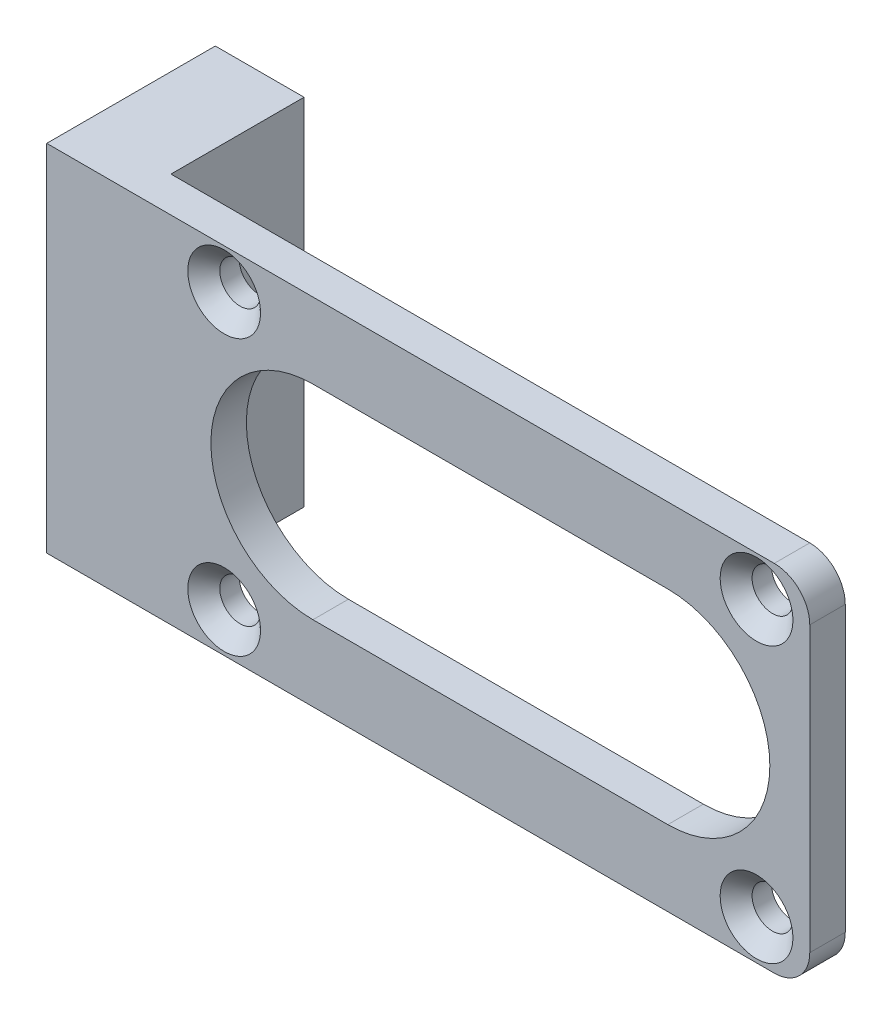
from build123d import *

# Parameters (mm, degrees)
SKETCH1_W           = 38
SKETCH1_H           = 20
BOSS_EXTRUDE1_DEPTH = 2
SKETCH2_W           = 5
SKETCH2_H           = 20
BOSS_EXTRUDE2_DEPTH = 7
M3_TAPPED_HOLE1_D   = 2.5
SKETCH7_R           = 1.15
CUT_EXTRUDE1_DEPTH  = 7.5
CUT_EXTRUDE2_DEPTH  = 7.5
SKETCH9_W           = 5
SKETCH9_H           = 20
BOSS_EXTRUDE3_DEPTH = 2.5
FILLET1_R           = 2
CHAMFER1_SIZE       = 0.9


with BuildPart() as part:
    # Sketch1 → Boss-Extrude1 (new body)
    with BuildSketch(Plane.XY):
        with Locations((19, 10)):
            Rectangle(SKETCH1_W, SKETCH1_H)
    extrude(amount=BOSS_EXTRUDE1_DEPTH)

    # Sketch2 → Boss-Extrude2 (add)
    with BuildSketch(Plane.XY.offset(2)):
        with Locations((-2.5, 10)):
            Rectangle(SKETCH2_W, SKETCH2_H)
    extrude(amount=-BOSS_EXTRUDE2_DEPTH)

    # M3 Tapped Hole1 (through all)
    with Locations(Plane(origin=(-5, 10, -2.5), x_dir=(0, -1, 0), z_dir=(-1, 0, 0))):
        with Locations((0, 0)):
            Hole(M3_TAPPED_HOLE1_D / 2)

    # Sketch7 → Cut-Extrude1 (cut)
    with BuildSketch(Plane.XY.offset(2)):
        with Locations((35, 17.75)):
            Circle(SKETCH7_R)
        with Locations((5, 17.75)):
            Circle(SKETCH7_R)
        with Locations((35, 2.25)):
            Circle(SKETCH7_R)
        with Locations((5, 2.25)):
            Circle(SKETCH7_R)
    extrude(amount=-CUT_EXTRUDE1_DEPTH, mode=Mode.SUBTRACT)

    # Sketch8 → Cut-Extrude2 (cut)
    with BuildSketch(Plane.XY.offset(2)):
        with BuildLine():
            Line((30, 4.25), (10, 4.25))
            ThreePointArc((10, 4.25), (4.25, 10), (10, 15.75))
            Line((10, 15.75), (30, 15.75))
            ThreePointArc((30, 15.75), (35.75, 10), (30, 4.25))
        make_face()
    extrude(amount=-CUT_EXTRUDE2_DEPTH, mode=Mode.SUBTRACT)

    # Sketch9 → Boss-Extrude3 (add)
    with BuildSketch(Plane(origin=(0, 0, -5), x_dir=(-1, 0, 0), z_dir=(0, 0, -1))):
        with Locations((2.5, 10)):
            Rectangle(SKETCH9_W, SKETCH9_H)
    extrude(amount=BOSS_EXTRUDE3_DEPTH)

    # Fillet1
    fillet1_edges = [part.edges().sort_by_distance(p)[0] for p in [
        (38, 20, 1),
        (38, 0, 1),
    ]]
    fillet(fillet1_edges, radius=FILLET1_R)

    # Chamfer1
    chamfer1_edges = [part.edges().sort_by_distance(p)[0] for p in [
        (3.85, 17.75, 2),
        (33.85, 2.25, 2),
        (3.85, 2.25, 2),
        (33.85, 17.75, 2),
    ]]
    chamfer(chamfer1_edges, length=CHAMFER1_SIZE)


solid = part.part
